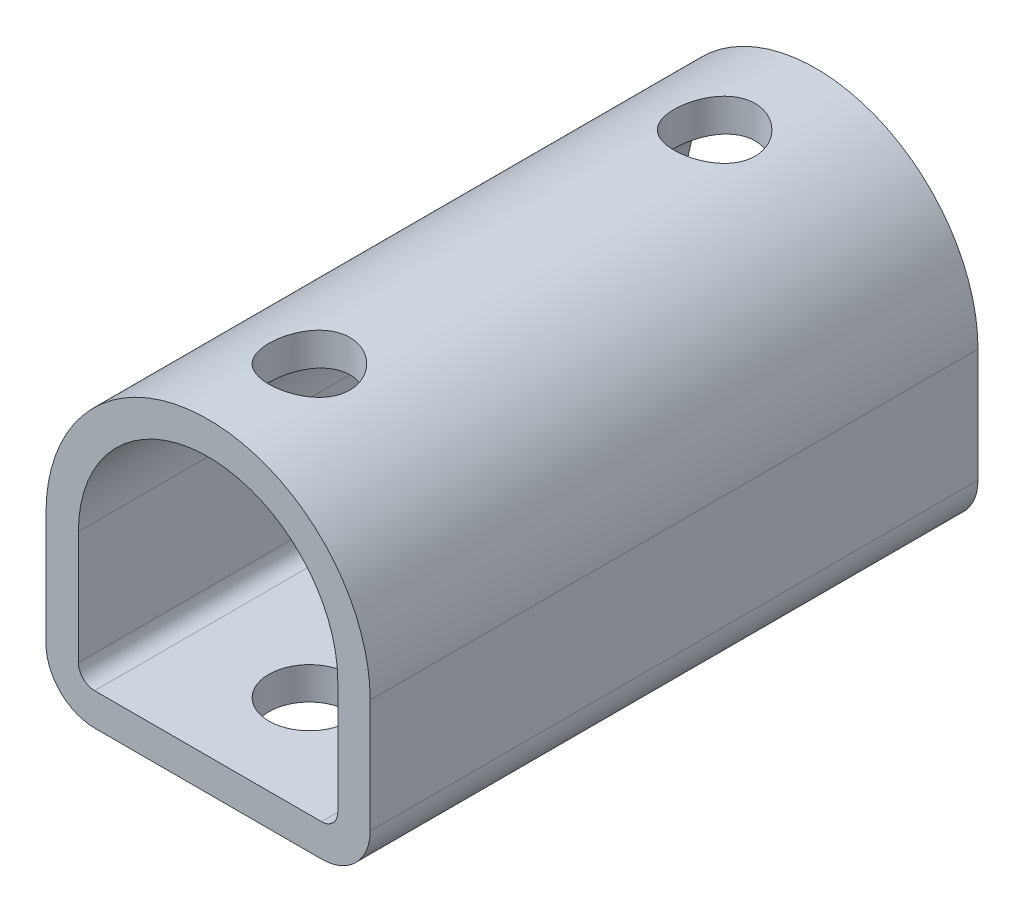
from build123d import *

# Parameters (mm, degrees)
SALIENTE_EXTRUIR1_DEPTH       = 37.5
PERCEUSE_COLONNE_POUR_M1_61_D = 10


with BuildPart() as part:
    # Croquis1 → Saliente-Extruir1 (new body, symmetric)
    with BuildSketch(Plane.XY):
        with BuildLine():
            Line((-20, 0), (-20, -14))
            ThreePointArc((-20, -14), (-18.242640687, -18.242640687), (-14, -20))
            Line((-14, -20), (14, -20))
            ThreePointArc((14, -20), (18.242640687, -18.242640687), (20, -14))
            Line((20, -14), (20, 0))
            ThreePointArc((20, 0), (0, 20), (-20, 0))
        make_face()
        with BuildLine():
            Line((-16, 0), (-16, -14))
            ThreePointArc((-16, -14), (-15.414213562, -15.414213562), (-14, -16))
            Line((-14, -16), (14, -16))
            ThreePointArc((14, -16), (15.414213562, -15.414213562), (16, -14))
            Line((16, -14), (16, 0))
            ThreePointArc((16, 0), (0, 16), (-16, 0))
        make_face(mode=Mode.SUBTRACT)
    extrude(amount=SALIENTE_EXTRUIR1_DEPTH, both=True)

    # Perceuse à colonne pour M1.61 (through all)
    with Locations(Plane(origin=(0, -20, 0), x_dir=(-1, 0, 0), z_dir=(0, -1, 0))):
        with Locations((0, -25), (0, 25)):
            Hole(PERCEUSE_COLONNE_POUR_M1_61_D / 2)


solid = part.part
